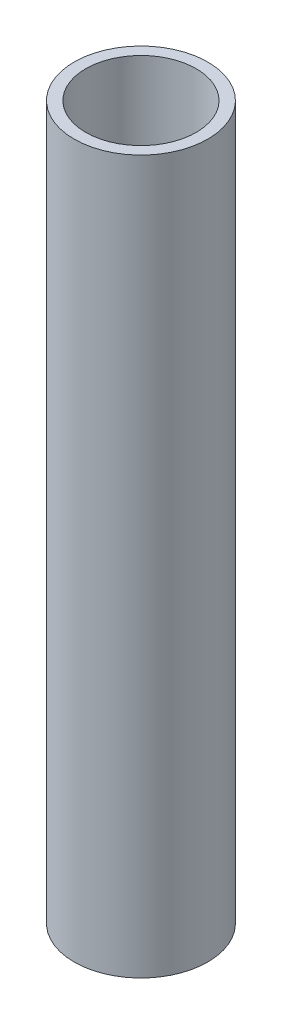
from build123d import *

# Parameters (mm, degrees)
SKETCH1_R   = 9.525
SKETCH1_R_2 = 7.874


with BuildPart() as part:
    # Sweep1: sweep along a path in Sketch2
    with BuildLine(Plane.XY) as sweep1_path:
        Line((0, 0), (0, 101.6))
    # Sketch1 → Sweep1 (sweep)
    with BuildSketch(Plane(origin=(0, 0, 0), x_dir=(1, 0, 0), z_dir=(0, 1, 0))):
        Circle(SKETCH1_R)
        Circle(SKETCH1_R_2, mode=Mode.SUBTRACT)
    sweep(path=sweep1_path.line)


solid = part.part
